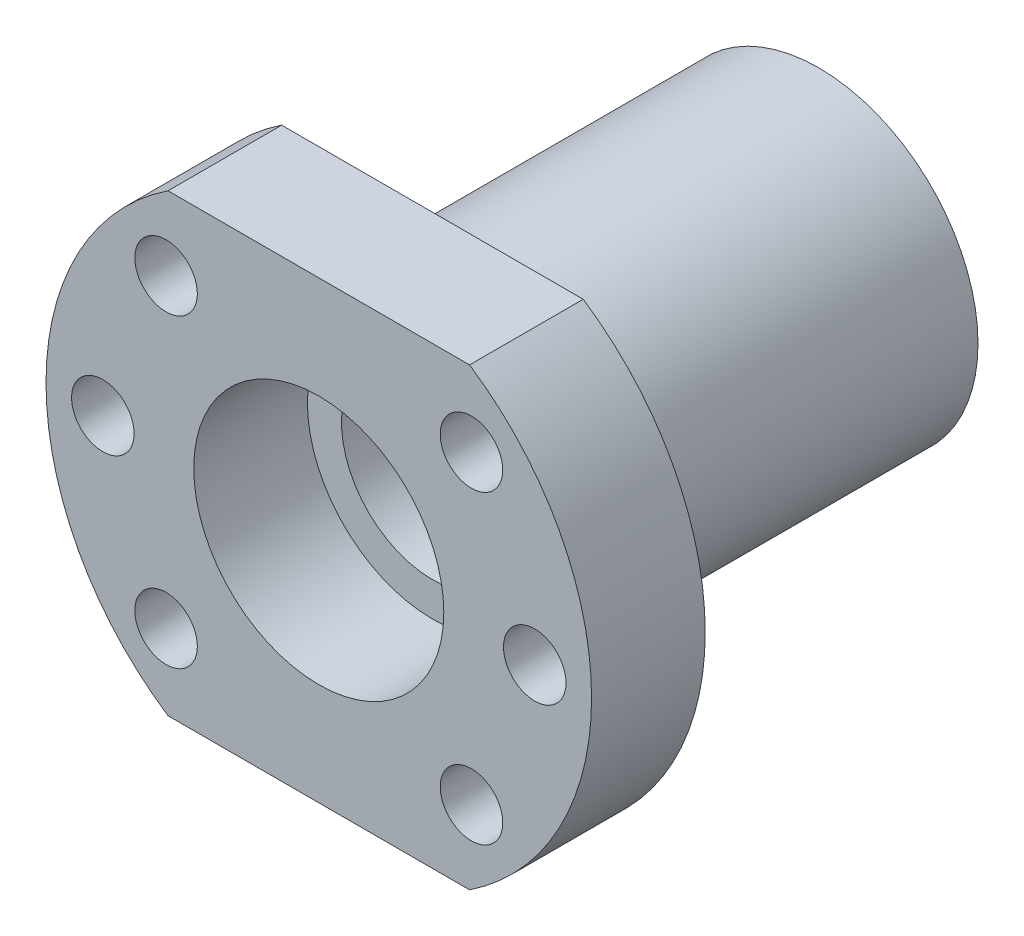
from build123d import *

# Parameters (mm, degrees)
SKETCH5_W          = 40
SKETCH5_H          = 10
CUT_EXTRUDE3_DEPTH = 45
SKETCH6_R          = 2.75
CUT_EXTRUDE4_DEPTH = 45


with BuildPart() as part:
    # Sketch4 → Revolve2 (revolve)
    with BuildSketch(Plane(origin=(0, 0, 0), x_dir=(0, 0, -1), z_dir=(1, 0, 0))):
        Polygon((22, 11), (12, 11), (12, 8), (-12, 8), (-12, 11), (-22, 11), (-22, 24), (-12, 24), (-12, 14), (22, 14), align=None)
    revolve(axis=Axis((0, 0, 17.928277082), (0, 0, -1)))

    # Sketch5 → Cut-Extrude3 (cut, through all)
    with BuildSketch(Plane.XY.offset(22)):
        with Locations((0, 25)):
            Rectangle(SKETCH5_W, SKETCH5_H)
        with Locations((0, -25)):
            Rectangle(SKETCH5_W, SKETCH5_H)
    extrude(amount=-CUT_EXTRUDE3_DEPTH, mode=Mode.SUBTRACT)

    # Sketch6 → Cut-Extrude4 (cut, through all)
    with BuildSketch(Plane.XY.offset(22)):
        with Locations((-19, 0)):
            Circle(SKETCH6_R)
        with Locations((-13.435028843, 13.435028843)):
            Circle(SKETCH6_R)
        with Locations((13.435028843, 13.435028843)):
            Circle(SKETCH6_R)
        with Locations((19, 0)):
            Circle(SKETCH6_R)
        with Locations((13.435028843, -13.435028843)):
            Circle(SKETCH6_R)
        with Locations((-13.435028843, -13.435028843)):
            Circle(SKETCH6_R)
    extrude(amount=-CUT_EXTRUDE4_DEPTH, mode=Mode.SUBTRACT)


solid = part.part
